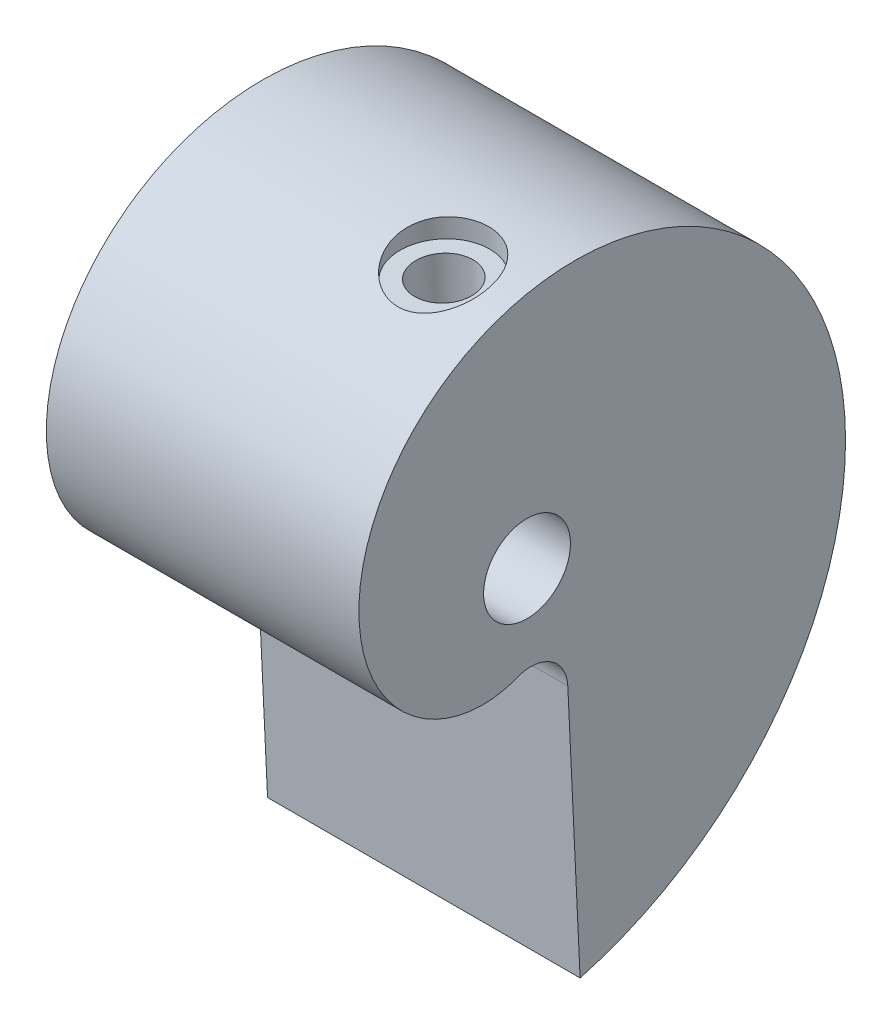
from build123d import *

# Parameters (mm, degrees)
SKETCH4_R                  = 3
BOSS_EXTRUDE1_DEPTH        = 21.59
CUT_EXTRUDE1_START         = -15.24
SKETCH8_R                  = 3.175
CUT_EXTRUDE1_DEPTH         = 5.08
F_10_32_TAPPED_HOLE1_D     = 4.0386
F_10_32_TAPPED_HOLE1_DEPTH = 13.8176
F_10_32_TAPPED_HOLE1_TIP   = 1.213317848


with BuildPart() as part:
    # Sketch4 → Boss-Extrude1 (new body)
    with BuildSketch(Plane(origin=(0, 0, 0), x_dir=(0, 0, -1), z_dir=(1, 0, 0))):
        with BuildLine():
            Line((3.667013126, -26.3254835), (2.816473307, -8.431236894))
            ThreePointArc((2.816473307, -8.431236894), (1.639602622, -6.396649217), (-0.700777066, -6.179406175))
            add(Edge.make_bspline(
                [(-0.700777066, -6.179406175), (-1.525102008, -6.512822326), (-2.494871997, -6.679047096), (-4.555429578, -6.54165034), (-5.644996058, -6.237076936), (-7.717261628, -5.106975392), (-8.698405735, -4.281093265), (-10.311829803, -2.164612563), (-10.942499326, -0.874358563), (-11.647480976, 2.006859472), (-11.720427957, 3.596803483), (-11.182779689, 6.826310345), (-10.571334953, 8.46432492), (-9.132019695, 10.73433891), (-8.566197708, 11.459621106), (-7.273120414, 12.810057002), (-6.545872807, 13.435152517), (-4.948692799, 14.549748502), (-4.078780417, 15.039192621), (-2.22269385, 15.85074605), (-1.236551533, 16.172803424), (0.818678144, 16.623204755), (1.887722789, 16.751503646), (4.069669804, 16.79483508), (5.182520117, 16.709831654), (7.408648574, 16.315055224), (8.521867273, 16.00525724), (10.70264063, 15.158359498), (11.770130786, 14.621247223), (13.812561896, 13.326727542), (14.787435905, 12.56932106), (16.598938448, 10.850935673), (17.435500393, 9.889971566), (18.927885533, 7.790674993), (19.583645356, 6.652371052), (20.677096627, 4.233429246), (21.114730733, 2.952832896), (21.741586229, 0.292117033), (21.930758945, -1.087949282), (22.038932986, -3.898444365), (21.957896657, -5.328810088), (21.513783431, -8.186144708), (21.150681858, -9.613043017), (20.141400668, -12.407098951), (19.49521083, -13.774181132), (17.930076055, -16.391877744), (17.011136269, -17.642414844), (14.922264044, -19.972214517), (13.752352434, -21.051401006), (11.194349378, -22.98792657), (9.80629411, -23.845193985), (6.855009859, -25.29377098), (5.291831431, -25.88501641), (3.667013126, -26.3254835)],
                knots=[0, 0, 0, 0, 0.0625, 0.0625, 0.125, 0.125, 0.1875, 0.1875, 0.25, 0.25, 0.3125, 0.3125, 0.375, 0.375, 0.40625, 0.40625, 0.4375, 0.4375, 0.46875, 0.46875, 0.5, 0.5, 0.53125, 0.53125, 0.5625, 0.5625, 0.59375, 0.59375, 0.625, 0.625, 0.65625, 0.65625, 0.6875, 0.6875, 0.71875, 0.71875, 0.75, 0.75, 0.78125, 0.78125, 0.8125, 0.8125, 0.84375, 0.84375, 0.875, 0.875, 0.90625, 0.90625, 0.9375, 0.9375, 0.96875, 0.96875, 1, 1, 1, 1], degree=3))
        make_face()
        Circle(SKETCH4_R, mode=Mode.SUBTRACT)
    extrude(amount=BOSS_EXTRUDE1_DEPTH)

    # Sketch8 → Cut-Extrude1 (cut)
    with BuildSketch(Plane(origin=(0, 0, 0), x_dir=(1, 0, 0), z_dir=(0, -0.9988722902167577, -0.04747786681317337)).offset(CUT_EXTRUDE1_START)):
        with Locations((16.565, 0)):
            Circle(SKETCH8_R)
    extrude(amount=-CUT_EXTRUDE1_DEPTH, mode=Mode.SUBTRACT)

    # 10-32 Tapped Hole1
    with Locations(Plane(origin=(0, 15.222813703, 0.72356269), x_dir=(1, 0, 0), z_dir=(0, 0.9988722902167577, 0.04747786681317337))):
        with Locations((16.565, 0)):
            Hole(F_10_32_TAPPED_HOLE1_D / 2, depth=F_10_32_TAPPED_HOLE1_DEPTH)
            with Locations((0, 0, -(F_10_32_TAPPED_HOLE1_DEPTH + F_10_32_TAPPED_HOLE1_TIP / 2))):  # 118° drill point
                Cone(0, F_10_32_TAPPED_HOLE1_D / 2, F_10_32_TAPPED_HOLE1_TIP, mode=Mode.SUBTRACT)


solid = part.part
